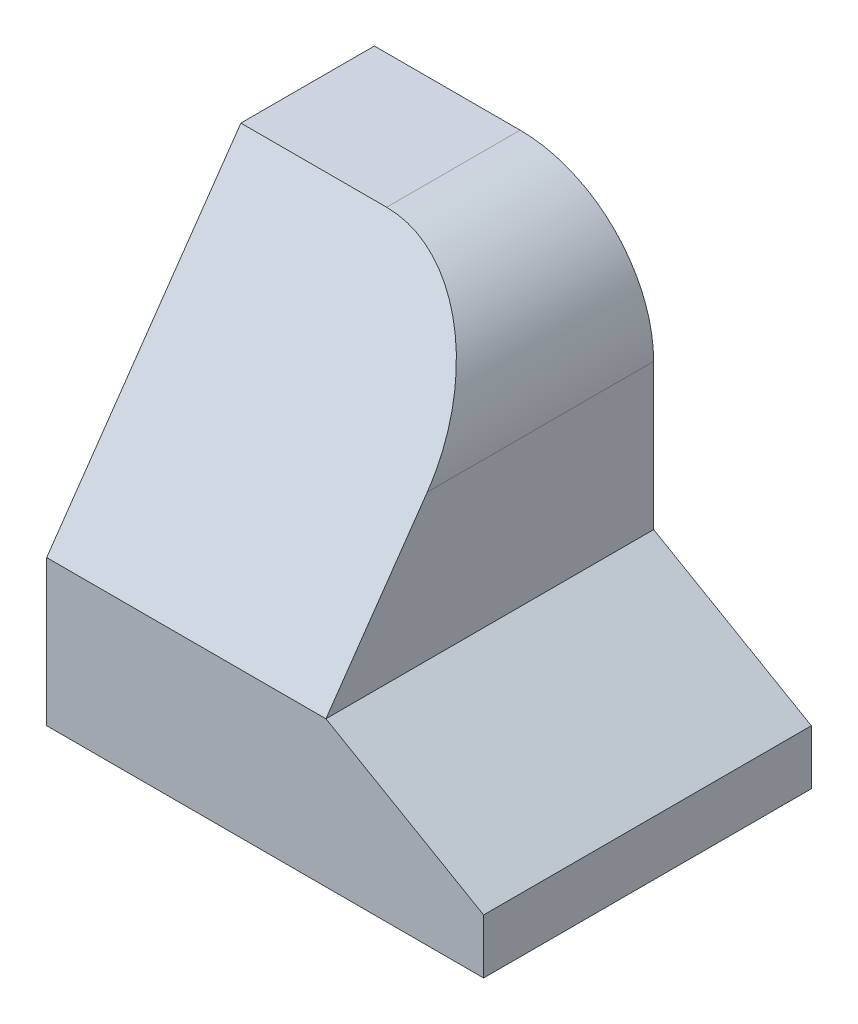
from build123d import *

# Parameters (mm, degrees)
EXTRUDE1_DEPTH = 54
EXTRUDE2_DEPTH = 47.019237886


with BuildPart() as part:
    # Sketch1 → Extrude1 (new body)
    with BuildSketch(Plane.XY):
        with BuildLine():
            Line((0, 0), (0, 70))
            Line((0, 70), (24.019237886, 70))
            ThreePointArc((24.019237886, 70), (39.575587073, 63.556349186), (46.019237886, 48))
            Line((46.019237886, 48), (46.019237886, 24))
            Line((46.019237886, 24), (72, 9))
            Line((72, 9), (72, 0))
            Line((72, 0), (0, 0))
        make_face()
    extrude(amount=EXTRUDE1_DEPTH)

    # Sketch2 → Extrude2 (cut, through all)
    with BuildSketch(Plane(origin=(46.019237886, 0, 0), x_dir=(0, 0, -1), z_dir=(1, 0, 0))):
        Polygon((-54, 24), (-22, 70), (-54, 70), align=None)
    extrude(amount=-EXTRUDE2_DEPTH, mode=Mode.SUBTRACT)


solid = part.part
